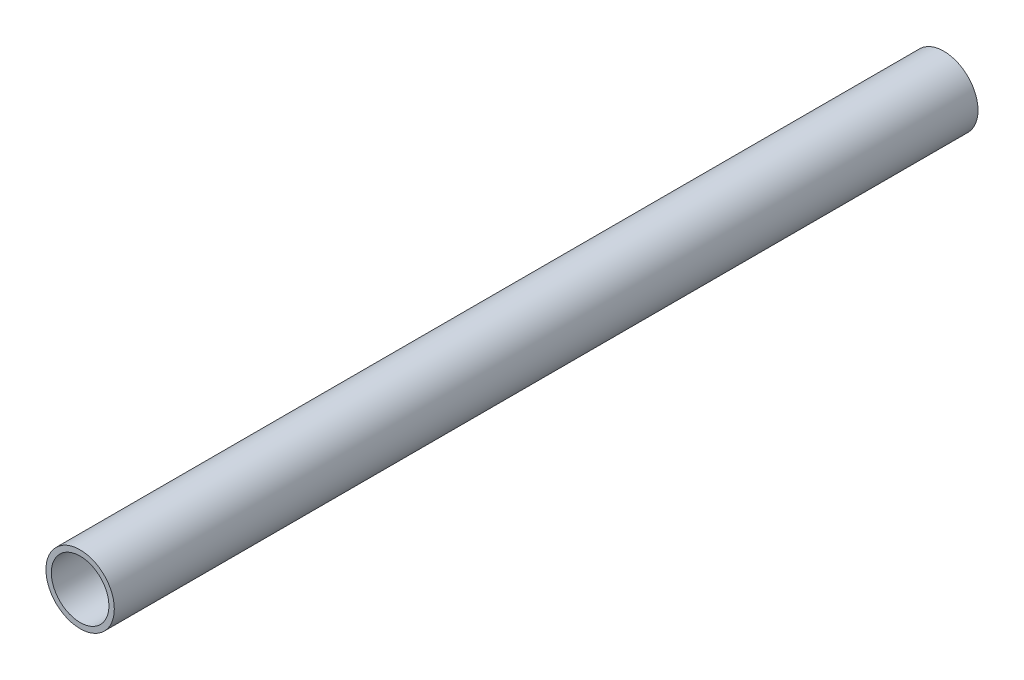
from build123d import *

# Parameters (mm, degrees)
SKETCH1_R           = 15.08125
SKETCH1_R_2         = 12.7
BOSS_EXTRUDE1_DEPTH = 381


with BuildPart() as part:
    # Sketch1 → Boss-Extrude1 (new body)
    with BuildSketch(Plane.XY):
        Circle(SKETCH1_R)
        Circle(SKETCH1_R_2, mode=Mode.SUBTRACT)
    extrude(amount=BOSS_EXTRUDE1_DEPTH)


solid = part.part
